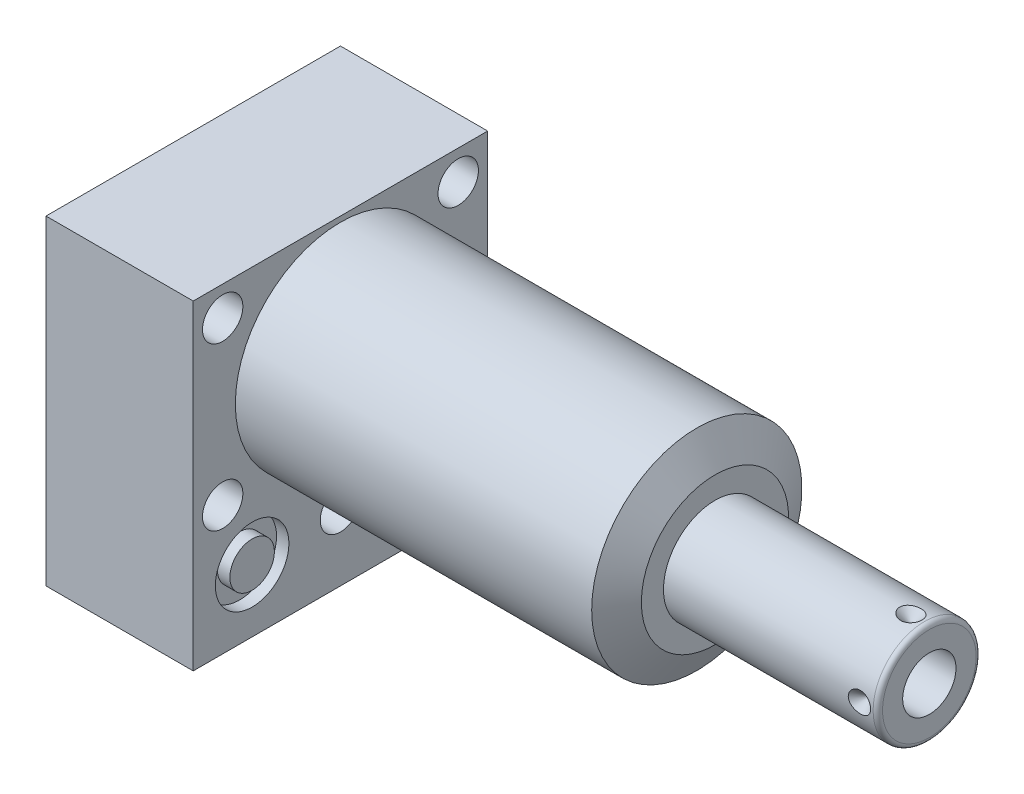
from build123d import *

# Parameters (mm, degrees)
SKETCH1_W           = 63.5
SKETCH1_H           = 69.088
EXTRUDE1_DEPTH      = 80.772
EXTRUDE1_DEPTH_BACK = 31.75
CUT_EXTRUDE1_REACH  = 82.772
SKETCH2_W           = 63.5
SKETCH2_H           = 69.088
SKETCH2_R           = 22.6695
SKETCH18_R          = 7.9375
CUT_EXTRUDE2_DEPTH  = 2.667
SKETCH19_R          = 7.9375
CUT_EXTRUDE3_DEPTH  = 2.667
SKETCH20_R          = 9.525
CUT_EXTRUDE4_DEPTH  = 0.254
SKETCH12_R          = 6.4389
EXTRUDE2_DEPTH      = 1.651
EXTRUDE3_START      = -31.75
SKETCH13_R          = 4.8006
EXTRUDE3_DEPTH      = 31.75
SKETCH14_R          = 1.7653
SKETCH15_R          = 1.7653
SKETCH21_W          = 4.3561
SKETCH21_H          = 31.75
HOLE1_AT_2_COUNT    = 2
HOLE1_AT_2_PITCH    = 54.58107178
HOLE1_AT_3_COUNT    = 2
HOLE1_AT_3_PITCH    = 34.9504
HOLE1_AT_4_COUNT    = 2
HOLE1_AT_4_PITCH    = 50.8
HOLE1_AT_5_COUNT    = 2
HOLE1_AT_5_PITCH    = 61.661742273
CIRPATTERN1_COUNT   = 4


with BuildPart() as part:
    # Sketch1 → Extrude1 (new body, two sides)
    with BuildSketch(Plane(origin=(0, 0, 0), x_dir=(0, 0, -1), z_dir=(1, 0, 0))) as extrude1_sk:
        with Locations((0, -10.7188)):
            Rectangle(SKETCH1_W, SKETCH1_H)
    extrude(amount=EXTRUDE1_DEPTH)
    extrude(extrude1_sk.sketch, amount=-EXTRUDE1_DEPTH_BACK)

    # Sketch2 → Cut-Extrude1 (cut, up to next)
    with BuildSketch(Plane(origin=(0, 0, 0), x_dir=(0, 0, -1), z_dir=(1, 0, 0)), mode=Mode.PRIVATE) as cut_extrude1_sk1:
        with Locations((0, -10.7188)):
            Rectangle(SKETCH2_W, SKETCH2_H)
        Circle(SKETCH2_R, mode=Mode.SUBTRACT)
    cut_extrude1_tool1 = extrude(cut_extrude1_sk1.sketch, amount=CUT_EXTRUDE1_REACH, mode=Mode.PRIVATE) & part.part
    add(cut_extrude1_tool1.solids().sort_by_distance((0, 22.886829, 0))[0], mode=Mode.SUBTRACT)

    # Sketch3 → Cut-Revolve1 (revolve, cut)
    with BuildSketch(Plane.XY, mode=Mode.PRIVATE) as cut_revolve1_sk:
        Polygon((76.849193596, 22.6695), (80.772, 15.875), (80.772, 22.6695), align=None)
    revolve(cut_revolve1_sk.sketch.rotate(Axis((76.037136009, 0, 0), (1, 0, 0)), 90), axis=Axis((76.037136009, 0, 0), (1, 0, 0)), mode=Mode.SUBTRACT)  # turned: the seam where the file's is

    # S2D0002 → Cut-Revolve2 (revolve, cut)
    with BuildSketch(Plane(origin=(-29.083, -31.75, 19.05), x_dir=(0, 1, 0), z_dir=(0, 0, 1)), mode=Mode.PRIVATE) as cut_revolve2_sk:
        Polygon((0, 0), (4.5466, 0), (4.106586662, -2.0701), (3.4544, -2.722286662), (3.4544, -13.97), (0, -13.97), align=None)
    revolve(cut_revolve2_sk.sketch.rotate(Axis((-14.4145, -31.75, 19.05), (-1, 0, 0)), 90), axis=Axis((-14.4145, -31.75, 19.05), (-1, 0, 0)), mode=Mode.SUBTRACT)  # turned: the seam where the file's is

    # Sketch5 → Cut-Revolve3 (revolve, cut)
    with BuildSketch(Plane(origin=(-29.083, -31.75, -19.05), x_dir=(0, 1, 0), z_dir=(0, 0, 1)), mode=Mode.PRIVATE) as cut_revolve3_sk:
        Polygon((0, 0), (4.5466, 0), (4.106586662, -2.0701), (3.4544, -2.722286662), (3.4544, -13.97), (0, -13.97), align=None)
    revolve(cut_revolve3_sk.sketch.rotate(Axis((-14.4145, -31.75, -19.05), (-1, 0, 0)), 90), axis=Axis((-14.4145, -31.75, -19.05), (-1, 0, 0)), mode=Mode.SUBTRACT)  # turned: the seam where the file's is

    # Sketch6 → Cut-Revolve4 (revolve, cut)
    with BuildSketch(Plane(origin=(-2.667, -31.75, 19.05), x_dir=(0, -1, 0), z_dir=(0, 0, 1)), mode=Mode.PRIVATE) as cut_revolve4_sk:
        Polygon((0, 0), (4.5466, 0), (4.106586662, -2.0701), (3.4544, -2.722286662), (3.4544, -12.192), (0, -12.192), align=None)
    revolve(cut_revolve4_sk.sketch.rotate(Axis((-15.4686, -31.75, 19.05), (1, 0, 0)), 90), axis=Axis((-15.4686, -31.75, 19.05), (1, 0, 0)), mode=Mode.SUBTRACT)  # turned: the seam where the file's is

    # Sketch7 → Cut-Revolve5 (revolve, cut)
    with BuildSketch(Plane(origin=(-2.667, -31.75, -19.05), x_dir=(0, -1, 0), z_dir=(0, 0, 1)), mode=Mode.PRIVATE) as cut_revolve5_sk:
        Polygon((0, 0), (4.5466, 0), (4.106586662, -2.0701), (3.4544, -2.722286662), (3.4544, -12.192), (0, -12.192), align=None)
    revolve(cut_revolve5_sk.sketch.rotate(Axis((-15.4686, -31.75, -19.05), (1, 0, 0)), 90), axis=Axis((-15.4686, -31.75, -19.05), (1, 0, 0)), mode=Mode.SUBTRACT)  # turned: the seam where the file's is

    # Sketch8 → Cut-Revolve6 (revolve, cut)
    with BuildSketch(Plane(origin=(-15.875, -51.6128, 19.05), x_dir=(-1, 0, 0), z_dir=(0, 0, 1)), mode=Mode.PRIVATE) as cut_revolve6_sk:
        Polygon((0, -6.604), (6.1849, -6.604), (5.642306865, -9.1567), (4.9784, -9.820606865), (4.9784, -25.654), (0, -25.654), align=None)
    revolve(cut_revolve6_sk.sketch.rotate(Axis((-15.875, -24.9428, 19.05), (0, -1, 0)), 270), axis=Axis((-15.875, -24.9428, 19.05), (0, -1, 0)), mode=Mode.SUBTRACT)  # turned: the seam where the file's is

    # Sketch9 → Cut-Revolve7 (revolve, cut)
    with BuildSketch(Plane(origin=(-15.875, -51.6128, -19.05), x_dir=(-1, 0, 0), z_dir=(0, 0, 1)), mode=Mode.PRIVATE) as cut_revolve7_sk:
        Polygon((0, -6.604), (6.1849, -6.604), (5.642306865, -9.1567), (4.9784, -9.820606865), (4.9784, -25.654), (0, -25.654), align=None)
    revolve(cut_revolve7_sk.sketch.rotate(Axis((-15.875, -24.9428, -19.05), (0, -1, 0)), 270), axis=Axis((-15.875, -24.9428, -19.05), (0, -1, 0)), mode=Mode.SUBTRACT)  # turned: the seam where the file's is

    # Sketch18 → Cut-Extrude2 (cut)
    with BuildSketch(Plane(origin=(0, 0, 0), x_dir=(0, 0, -1), z_dir=(1, 0, 0))):
        with Locations((-19.05, -31.75)):
            Circle(SKETCH18_R)
        with Locations((19.05, -31.75)):
            Circle(SKETCH18_R)
    extrude(amount=-CUT_EXTRUDE2_DEPTH, mode=Mode.SUBTRACT)

    # Sketch19 → Cut-Extrude3 (cut)
    with BuildSketch(Plane.ZY.offset(31.75)):
        with Locations(Location((-19.05, -31.75, 0), (0, 0, 180))):  # turned: the seam where the file's is
            Circle(SKETCH19_R)
        with Locations(Location((19.05, -31.75, 0), (0, 0, 180))):  # turned: the seam where the file's is
            Circle(SKETCH19_R)
    extrude(amount=-CUT_EXTRUDE3_DEPTH, mode=Mode.SUBTRACT)

    # Sketch20 → Cut-Extrude4 (cut)
    with BuildSketch(Plane.XZ.offset(45.2628)):
        with Locations(Location((-15.875, -19.05, 0), (0, 0, 270))):  # turned: the seam where the file's is
            Circle(SKETCH20_R)
        with Locations(Location((-15.875, 19.05, 0), (0, 0, 270))):  # turned: the seam where the file's is
            Circle(SKETCH20_R)
    extrude(amount=-CUT_EXTRUDE4_DEPTH, mode=Mode.SUBTRACT)

    # Sketch10 → Revolve1 (revolve)
    with BuildSketch(Plane.XY, mode=Mode.PRIVATE) as revolve1_sk:
        with BuildLine():
            Line((80.772, 0), (80.772, 11.1125))
            Line((80.772, 11.1125), (125.984, 11.1125))
            ThreePointArc((125.984, 11.1125), (126.70242049, 10.81492049), (127, 10.0965))
            Line((127, 10.0965), (127, 0))
            Line((127, 0), (80.772, 0))
        make_face()
    revolve(revolve1_sk.sketch.rotate(Axis((58.270820274, 0, 0), (1, 0, 0)), 90), axis=Axis((58.270820274, 0, 0), (1, 0, 0)))  # turned: the seam where the file's is

    # S2D0001 → Cut-Revolve8 (revolve, cut)
    with BuildSketch(Plane(origin=(118.6434, -5.7531, 0), x_dir=(0, -1, 0), z_dir=(0, 0, 1)), mode=Mode.PRIVATE) as cut_revolve8_sk:
        Polygon((0, 8.3566), (0, -8.6614), (-5.7531, -12.118211227), (-5.7531, 8.3566), align=None)
    revolve(cut_revolve8_sk.sketch.rotate(Axis((84.296273767, 0, 0), (1, 0, 0)), 270), axis=Axis((84.296273767, 0, 0), (1, 0, 0)), mode=Mode.SUBTRACT)  # turned: the seam where the file's is

    # Sketch12 → Extrude2 (add)
    with BuildSketch(Plane(origin=(-31.75, -45.0088, 0), x_dir=(0, 0, -1), z_dir=(0, -1, 0))):
        with Locations((-19.05, 15.875)):
            Circle(SKETCH12_R)
    extrude(amount=EXTRUDE2_DEPTH)

    # Sketch13 → Extrude3 (add)
    with BuildSketch(Plane(origin=(0, 0, 0), x_dir=(0, 0, -1), z_dir=(1, 0, 0)).offset(EXTRUDE3_START)):
        with Locations((-19.05, -31.75)):
            Circle(SKETCH13_R)
    extrude(amount=EXTRUDE3_DEPTH)

    # Sketch16 → Cut-Revolve9 (revolve, cut)
    with BuildSketch(Plane(origin=(114.681, 11.1125, 0), x_dir=(-1, 0, 0), z_dir=(0, 0, -1)), mode=Mode.PRIVATE) as cut_revolve9_sk:
        Polygon((-8.3566, 0), (-5.9436, 0), (-8.3566, -2.413), align=None)
    cut_revolve9 = revolve(cut_revolve9_sk.sketch.rotate(Axis((123.0376, 6.093194843, 0), (0, 1, 0)), 90), axis=Axis((123.0376, 6.093194843, 0), (0, 1, 0)), mode=Mode.SUBTRACT)  # turned: the seam where the file's is

    # Sketch21 → Hole1 (revolve, cut)
    with BuildSketch(Plane(origin=(0, 17.4752, 25.4), x_dir=(0, 0, -1), z_dir=(0, 1, 0))):
        with Locations((2.17805, 15.875)):
            Rectangle(SKETCH21_W, SKETCH21_H)
    hole1 = revolve(axis=Axis((-110, 17.4752, 25.4), (1, 0, 0)), mode=Mode.SUBTRACT)

    # Hole1 at 2: Hole1 ×2
    with Locations(*[Vector(0, -0.885120032, -0.465362793) * (i * HOLE1_AT_2_PITCH) for i in range(1, HOLE1_AT_2_COUNT)]):
        add(hole1, mode=Mode.SUBTRACT)

    # Hole1 at 3: Hole1 ×2
    with Locations(*[(0, -i * HOLE1_AT_3_PITCH, 0) for i in range(1, HOLE1_AT_3_COUNT)]):
        add(hole1, mode=Mode.SUBTRACT)

    # Hole1 at 4: Hole1 ×2
    with Locations(*[(0, 0, -i * HOLE1_AT_4_PITCH) for i in range(1, HOLE1_AT_4_COUNT)]):
        add(hole1, mode=Mode.SUBTRACT)

    # Hole1 at 5: Hole1 ×2
    with Locations(*[Vector(0, -0.566808506, -0.823849572) * (i * HOLE1_AT_5_PITCH) for i in range(1, HOLE1_AT_5_COUNT)]):
        add(hole1, mode=Mode.SUBTRACT)

    # CirPattern1: Cut-Revolve9 ×4 about axis
    cirpattern1_axis = Axis((58.270820274, 0, 0), (-1, 0, 0))
    for i in range(1, CIRPATTERN1_COUNT):
        add(cut_revolve9.rotate(cirpattern1_axis, i * 360 / CIRPATTERN1_COUNT), mode=Mode.SUBTRACT)


with BuildPart() as body_2:
    # Sketch14 → Revolve2 (revolve)
    with BuildSketch(Plane(origin=(0, -31.75, -19.05), x_dir=(0, 0, -1), z_dir=(0, -1, 0)), mode=Mode.PRIVATE) as revolve2_sk:
        with Locations((6.1722, -0.9017)):
            Circle(SKETCH14_R)
    revolve(revolve2_sk.sketch.rotate(Axis((-2.84353, -31.75, -19.05), (1, 0, 0)), 180), axis=Axis((-2.84353, -31.75, -19.05), (1, 0, 0)))  # turned: the seam where the file's is


with BuildPart() as body_3:
    # Sketch15 → Revolve3 (revolve)
    with BuildSketch(Plane(origin=(0, -31.75, -19.05), x_dir=(0, 0, -1), z_dir=(0, -1, 0)), mode=Mode.PRIVATE) as revolve3_sk:
        with Locations((6.1722, -30.8483)):
            Circle(SKETCH15_R)
    revolve(revolve3_sk.sketch.rotate(Axis((-32.79013, -31.75, -19.05), (1, 0, 0)), 180), axis=Axis((-32.79013, -31.75, -19.05), (1, 0, 0)))  # turned: the seam where the file's is


solid = Compound([part.part, body_2.part, body_3.part])
